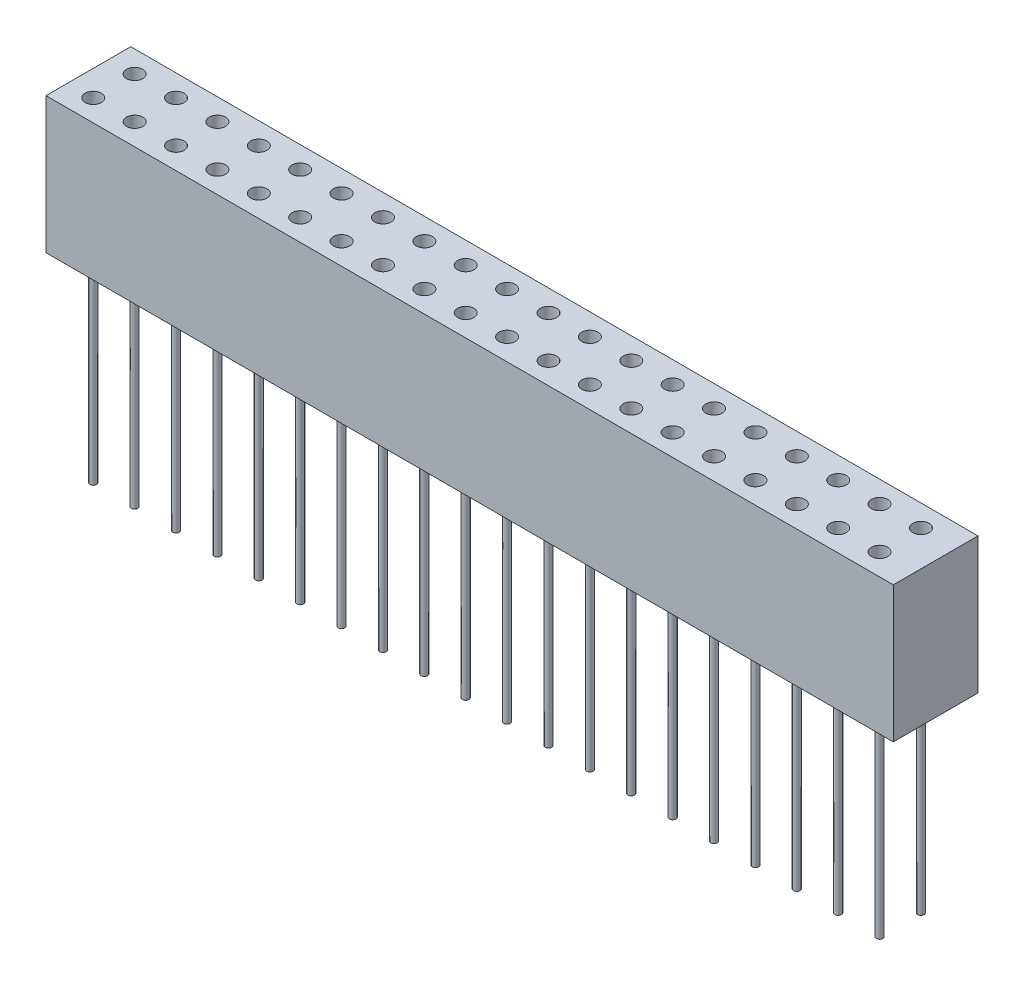
from build123d import *

# Parameters (mm, degrees)
SKETCH1_W           = 52
SKETCH1_H           = 5.2
BOSS_EXTRUDE1_DEPTH = 8.35
SKETCH2_R           = 0.5
CUT_EXTRUDE1_DEPTH  = 3
SKETCH3_R           = 0.2
BOSS_EXTRUDE2_DEPTH = 12.1
LPATTERN1_COUNT     = 20
LPATTERN1_PITCH     = 2.54


with BuildPart() as part:
    # Sketch1 → Boss-Extrude1 (new body)
    with BuildSketch(Plane(origin=(0, 0, 0), x_dir=(1, 0, 0), z_dir=(0, 1, 0))):
        Rectangle(SKETCH1_W, SKETCH1_H)
    extrude(amount=BOSS_EXTRUDE1_DEPTH)

    # Sketch2 → Cut-Extrude1 (cut)
    with BuildSketch(Plane(origin=(0, 8.35, 0), x_dir=(1, 0, 0), z_dir=(0, 1, 0))):
        with Locations((-24.43, 1.27)):
            Circle(SKETCH2_R)
        with Locations((-24.43, -1.27)):
            Circle(SKETCH2_R)
    cut_extrude1 = extrude(amount=-CUT_EXTRUDE1_DEPTH, mode=Mode.SUBTRACT)

    # Sketch3 → Boss-Extrude2 (add)
    with BuildSketch(Plane.XZ):
        with Locations((-24.43, 1.27)):
            Circle(SKETCH3_R)
        with Locations((-24.43, -1.27)):
            Circle(SKETCH3_R)
    boss_extrude2 = extrude(amount=BOSS_EXTRUDE2_DEPTH)

    # LPattern1: Cut-Extrude1, Boss-Extrude2 ×20
    with Locations(*[(i * LPATTERN1_PITCH, 0, 0) for i in range(1, LPATTERN1_COUNT)]):
        add(cut_extrude1, mode=Mode.SUBTRACT)
        add(boss_extrude2)


solid = part.part
